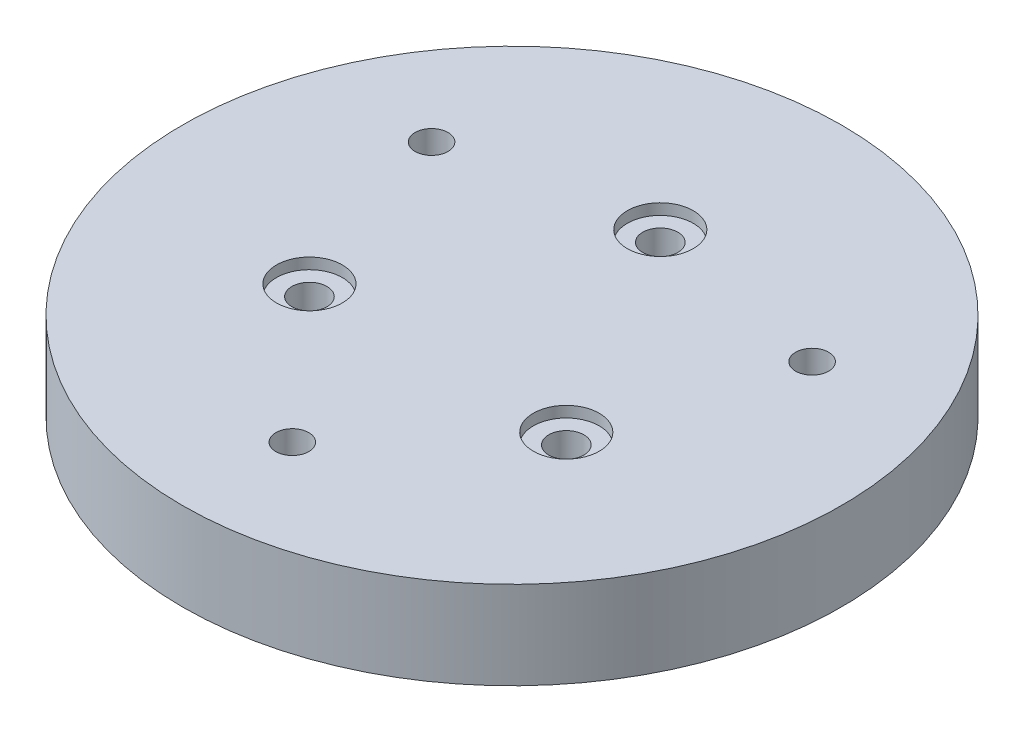
from build123d import *

# Parameters (mm, degrees)
SKETCH_1_R          = 30
EXTRUDE_1_DEPTH     = 8
SKETCH_2_R          = 1.6
CUT_EXTRUDE_1_DEPTH = 15
SKETCH_3_R          = 1.5
CUT_EXTRUDE_2_DEPTH = 8
SKETCH_4_R          = 3
CUT_EXTRUDE_3_DEPTH = 1
SKETCH_5_R          = 1.5
CUT_EXTRUDE_4_DEPTH = 4


with BuildPart() as part:
    # 草图1 → 凸台-拉伸1 (new body)
    with BuildSketch(Plane(origin=(0, 0, 0), x_dir=(1, 0, 0), z_dir=(0, 1, 0))):
        Circle(SKETCH_1_R)
    extrude(amount=EXTRUDE_1_DEPTH)

    # 草图2 → 切除-拉伸1 (cut)
    with BuildSketch(Plane(origin=(0, 8, 0), x_dir=(1, 0, 0), z_dir=(0, 1, 0))):
        with Locations((0, 13.5)):
            Circle(SKETCH_2_R)
        with Locations((11.691342951, -6.75)):
            Circle(SKETCH_2_R)
        with Locations((-11.691342951, -6.75)):
            Circle(SKETCH_2_R)
    extrude(amount=-CUT_EXTRUDE_1_DEPTH, mode=Mode.SUBTRACT)

    # 草图3 → 切除-拉伸2 (cut)
    with BuildSketch(Plane(origin=(0, 8, 0), x_dir=(1, 0, 0), z_dir=(0, 1, 0))):
        with Locations((17.320508076, 10)):
            Circle(SKETCH_3_R)
        with Locations((0, -20)):
            Circle(SKETCH_3_R)
        with Locations((-17.320508076, 10)):
            Circle(SKETCH_3_R)
    extrude(amount=-CUT_EXTRUDE_2_DEPTH, mode=Mode.SUBTRACT)

    # 草图4 → 切除-拉伸3 (cut)
    with BuildSketch(Plane(origin=(0, 8, 0), x_dir=(1, 0, 0), z_dir=(0, 1, 0))):
        with Locations((0, 13.5)):
            Circle(SKETCH_4_R)
        with Locations((11.691342951, -6.75)):
            Circle(SKETCH_4_R)
        with Locations((-11.691342951, -6.75)):
            Circle(SKETCH_4_R)
    extrude(amount=-CUT_EXTRUDE_3_DEPTH, mode=Mode.SUBTRACT)

    # 草图5 → 切除-拉伸4 (cut)
    with BuildSketch(Plane.XZ):
        Polygon((-14.722431864, -10), (-16.02146997, -7.75), (-18.619546181, -7.75), (-19.918584287, -10), (-18.619546181, -12.25), (-16.02146997, -12.25), align=None)
        with Locations((-17.320508076, -10)):
            Circle(SKETCH_5_R, mode=Mode.SUBTRACT)
        Polygon((16.02146997, -7.75), (14.722431864, -10), (16.02146997, -12.25), (18.619546181, -12.25), (19.918584287, -10), (18.619546181, -7.75), align=None)
        with Locations((17.320508076, -10)):
            Circle(SKETCH_5_R, mode=Mode.SUBTRACT)
        Polygon((1.299038106, 22.25), (-1.299038106, 22.25), (-2.598076211, 20), (-1.299038106, 17.75), (1.299038106, 17.75), (2.598076211, 20), align=None)
    extrude(amount=-CUT_EXTRUDE_4_DEPTH, mode=Mode.SUBTRACT)


solid = part.part
